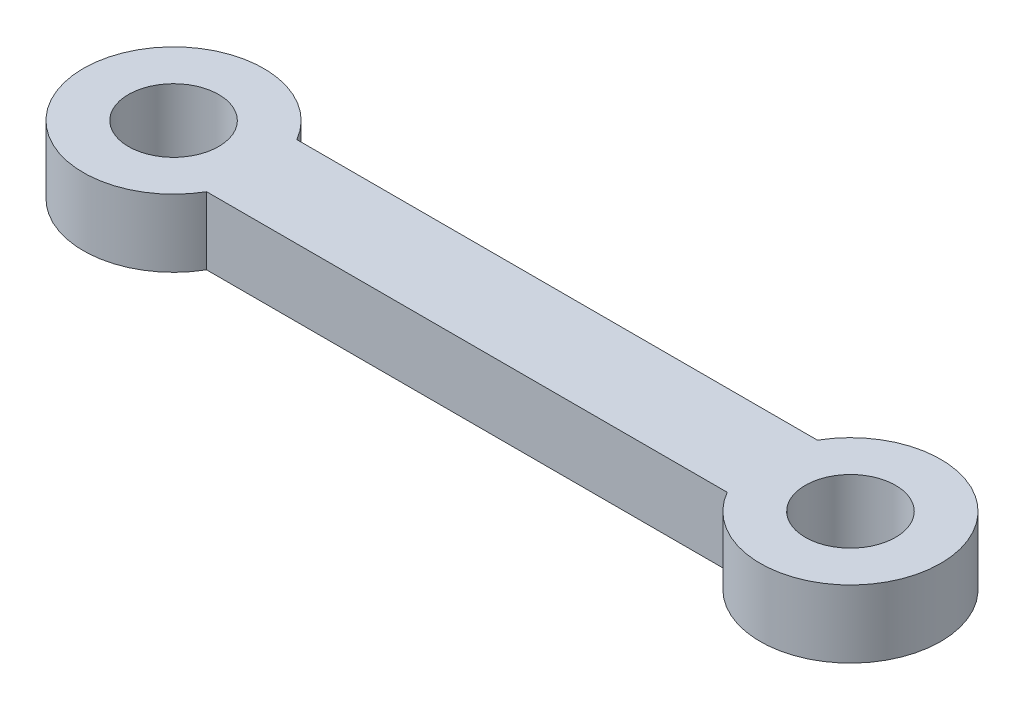
from build123d import *

# Parameters (mm, degrees)
BOSS_EXTRUDE1_DEPTH = 15
F_20_0MM_1_D        = 20
SCALE_1_SCALE       = 0.3


with BuildPart() as part:
    # Sketch1 → Boss-Extrude1 (new body)
    with BuildSketch(Plane(origin=(0, 0, 0), x_dir=(1, 0, 0), z_dir=(0, 1, 0))):
        with BuildLine():
            Line((57.679491924, 10), (-57.679491924, 10))
            ThreePointArc((-57.679491924, 10), (-95, 0), (-57.679491924, -10))
            Line((-57.679491924, -10), (57.679491924, -10))
            ThreePointArc((57.679491924, -10), (95, 0), (57.679491924, 10))
        make_face()
    extrude(amount=BOSS_EXTRUDE1_DEPTH)

    # Ø20.0mm 맞춤핀 구멍1 (through all)
    with Locations(Plane(origin=(0, 15, 0), x_dir=(1, 0, 0), z_dir=(0, 1, 0))):
        with Locations((-75, 0), (75, 0)):
            Hole(F_20_0MM_1_D / 2)


with BuildPart() as part_1:
    # 축척1: scaled about (0, 7.5, 0)
    add(part.part.scale(SCALE_1_SCALE).moved(Location((0, 5.25, 0))))


solid = part_1.part
